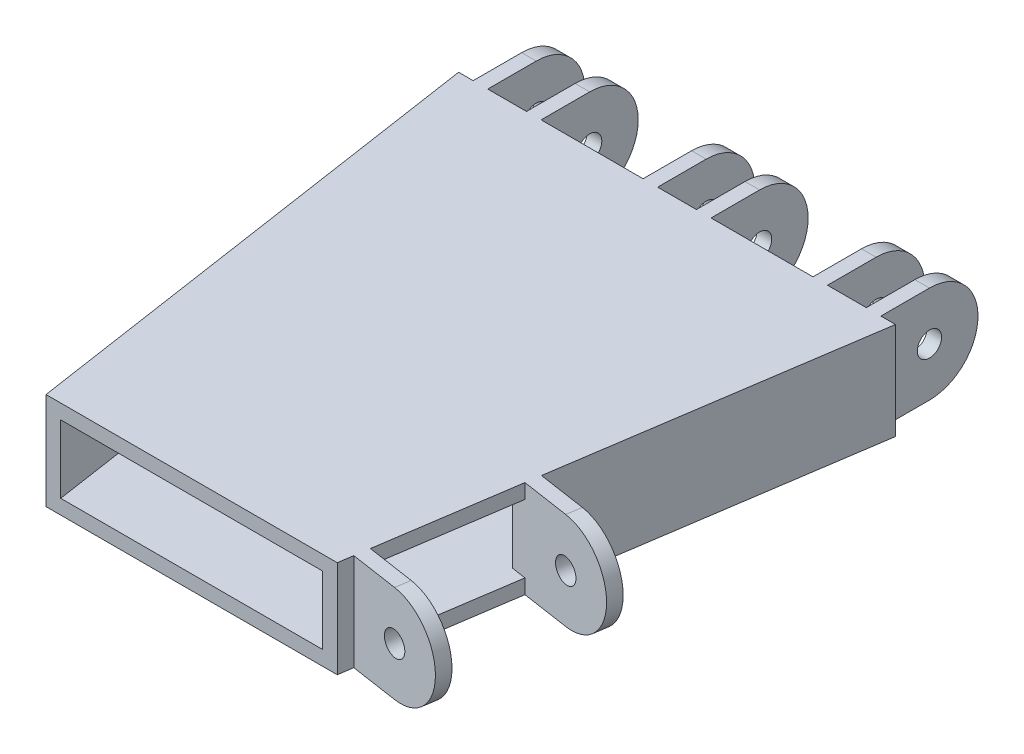
from build123d import *

# Parameters (mm, degrees)
BOSS_EXTRUDE1_DEPTH = 10
BOSS_EXTRUDE2_START = 35
SKETCH2_R           = 2.5
BOSS_EXTRUDE2_DEPTH = 7
LPATTERN1_COUNT     = 3
LPATTERN1_PITCH     = 35
SHELL1_T            = -3
SKETCH3_W           = 8
SKETCH3_H           = 20
CUT_EXTRUDE1_DEPTH  = 20
BOSS_EXTRUDE3_START = -3
SKETCH5_R           = 2.5
BOSS_EXTRUDE3_DEPTH = 3
LPATTERN2_COUNT     = 2
LPATTERN2_PITCH     = 31
SKETCH6_W           = 28
SKETCH6_H           = 14
CUT_EXTRUDE2_DEPTH  = 3


with BuildPart() as part:
    # Sketch1 → Boss-Extrude1 (new body, symmetric)
    with BuildSketch(Plane(origin=(0, 0, 0), x_dir=(1, 0, 0), z_dir=(0, 1, 0))):
        Polygon((-45, 0), (45, 0), (30, -100), (-30, -100), align=None)
    extrude(amount=BOSS_EXTRUDE1_DEPTH, both=True)

    # Sketch2 → Boss-Extrude2 (add, symmetric)
    with BuildSketch(Plane(origin=(0, 0, 0), x_dir=(0, 0, -1), z_dir=(1, 0, 0)).offset(BOSS_EXTRUDE2_START)):
        with BuildLine():
            Line((0, 10), (10, 10))
            ThreePointArc((10, 10), (20, 0), (10, -10))
            Line((10, -10), (0, -10))
            Line((0, -10), (0, 10))
        make_face()
        with Locations((10, 0)):
            Circle(SKETCH2_R, mode=Mode.SUBTRACT)
    boss_extrude2 = extrude(amount=BOSS_EXTRUDE2_DEPTH, both=True)

    # LPattern1: Boss-Extrude2 ×3
    with Locations(*[(-i * LPATTERN1_PITCH, 0, 0) for i in range(1, LPATTERN1_COUNT)]):
        add(boss_extrude2)

    # Shell1
    shell1_openings = [part.faces().sort_by_distance(p)[0] for p in [
        (0, 0, 100),
    ]]
    offset(amount=SHELL1_T, openings=shell1_openings, kind=Kind.INTERSECTION)

    # Sketch3 → Cut-Extrude1 (cut)
    with BuildSketch(Plane.XY):
        with Locations((35, 0)):
            Rectangle(SKETCH3_W, SKETCH3_H)
        Rectangle(SKETCH3_W, SKETCH3_H)
        with Locations((-35, 0)):
            Rectangle(SKETCH3_W, SKETCH3_H)
    extrude(amount=-CUT_EXTRUDE1_DEPTH, mode=Mode.SUBTRACT)

    # Sketch5 → Boss-Extrude3 (add)
    with BuildSketch(Plane(origin=(-14.009779951, 0, 93.398533007), x_dir=(0.988936353, 0, 0.148340453), z_dir=(-0.148340453, 0, 0.988936353)).offset(BOSS_EXTRUDE3_START)):
        with BuildLine():
            Line((44.502135879, 10), (54.502135879, 10))
            ThreePointArc((54.502135879, 10), (64.502135879, 0), (54.502135879, -10))
            Line((54.502135879, -10), (44.502135879, -10))
            Line((44.502135879, -10), (44.502135879, 10))
        make_face()
        with Locations((54.502135879, 0)):
            Circle(SKETCH5_R, mode=Mode.SUBTRACT)
    boss_extrude3 = extrude(amount=-BOSS_EXTRUDE3_DEPTH)

    # LPattern2: Boss-Extrude3 ×2
    with Locations(*[Vector(0.148340453, 0, -0.988936353) * (i * LPATTERN2_PITCH) for i in range(1, LPATTERN2_COUNT)]):
        add(boss_extrude3)

    # Sketch6 → Cut-Extrude2 (cut)
    with BuildSketch(Plane(origin=(44.009779951, 0, 6.601466993), x_dir=(0.148340453, 0, -0.988936353), z_dir=(0.988936353, 0, 0.148340453))):
        with Locations((-74.443421699, 0)):
            Rectangle(SKETCH6_W, SKETCH6_H)
    extrude(amount=-CUT_EXTRUDE2_DEPTH, mode=Mode.SUBTRACT)


solid = part.part
